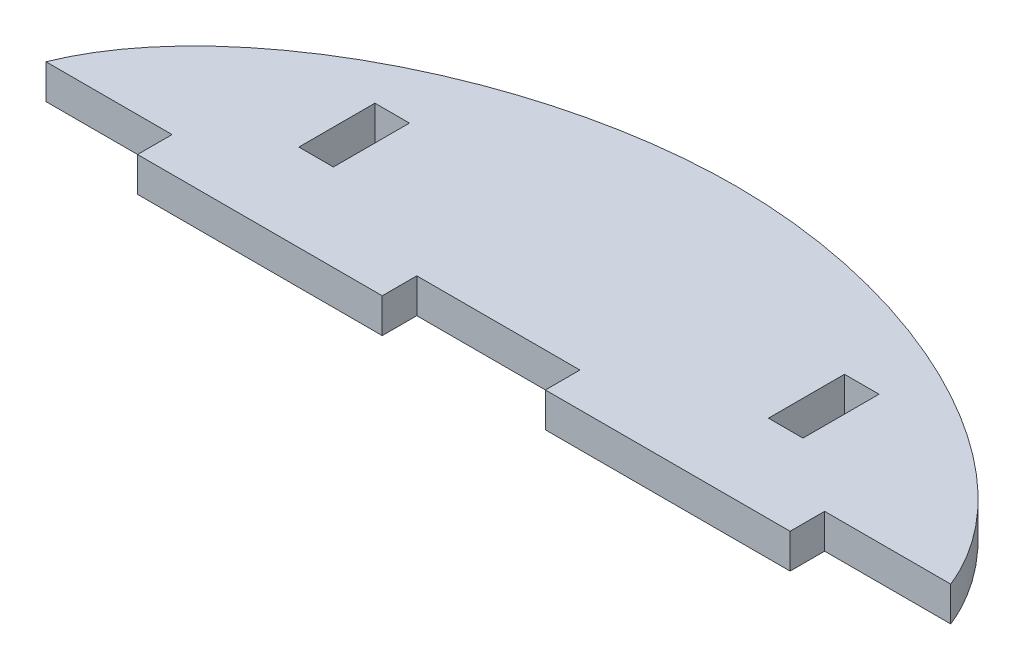
from build123d import *

# Parameters (mm, degrees)
BOSS_EXTRUDE1_DEPTH = 3.175
SKETCH2_W           = 3.175
SKETCH2_H           = 6.992
SKETCH2_W_2         = 12.5
SKETCH2_H_2         = 3.175
SKETCH2_W_3         = 15
CUT_EXTRUDE1_DEPTH  = 4.1750001


with BuildPart() as part:
    # Sketch1 → Boss-Extrude1 (new body)
    with BuildSketch(Plane(origin=(0, 0, 0), x_dir=(1, 0, 0), z_dir=(0, 1, 0))):
        with BuildLine():
            add(Edge.make_bspline(
                [(0, 0), (2.315309036, 13.13077004), (22.407654518, 25), (42.5, 25)],
                knots=[0, 0, 0, 0, 0.5, 0.5, 0.5, 0.5], degree=3))
            Line((0, 0), (42.5, 0))
            Line((42.5, 0), (42.5, 25))
        make_face()
        with BuildLine():
            Line((42.5, 25), (42.5, 0))
            Line((42.5, 0), (85, 0))
            add(Edge.make_bspline(
                [(42.5, 25), (62.592345482, 25), (82.684690964, 13.13077004), (85, 0)],
                knots=[0.5, 0.5, 0.5, 0.5, 1, 1, 1, 1], degree=3))
        make_face()
    extrude(amount=BOSS_EXTRUDE1_DEPTH)

    # Sketch2 → Cut-Extrude1 (cut, through all)
    with BuildSketch(Plane.XZ):
        with Locations((64.0875, -11.504)):
            Rectangle(SKETCH2_W, SKETCH2_H)
        with Locations((20.9125, -11.504)):
            Rectangle(SKETCH2_W, SKETCH2_H)
        with Locations((78.75, -1.5875)):
            Rectangle(SKETCH2_W_2, SKETCH2_H_2)
        with Locations((6.25, -1.5875)):
            Rectangle(SKETCH2_W_2, SKETCH2_H_2)
        with Locations((42.5, -1.5875)):
            Rectangle(SKETCH2_W_3, SKETCH2_H_2)
    extrude(amount=-CUT_EXTRUDE1_DEPTH, mode=Mode.SUBTRACT)


solid = part.part
